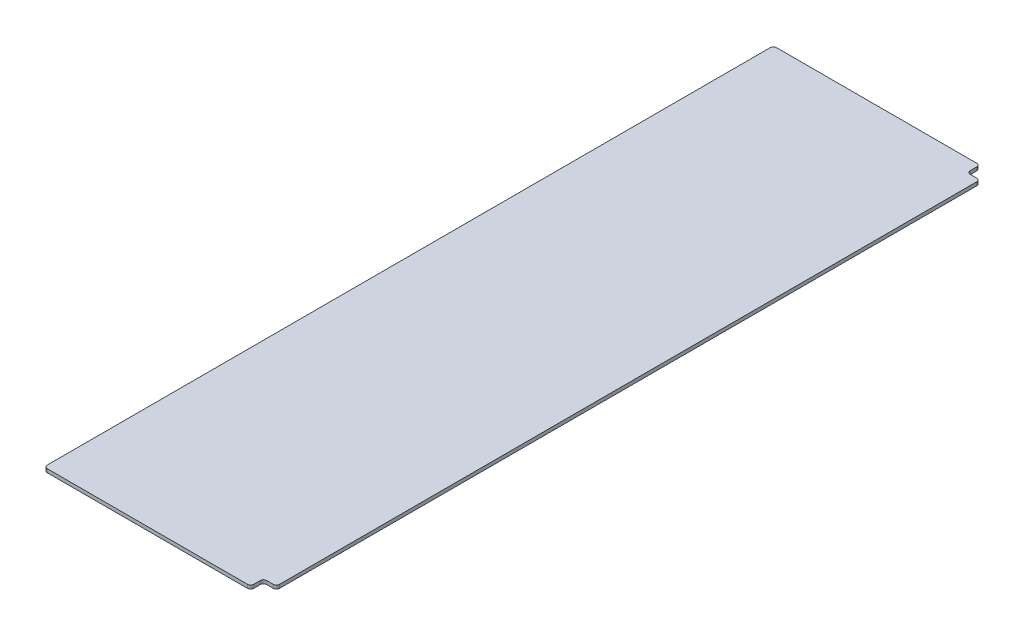
from build123d import *

# Parameters (mm, degrees)
SKETCH1_W           = 190.5
SKETCH1_H           = 609.6
BOSS_EXTRUDE1_DEPTH = 2.778125
SKETCH2_W           = 190.5
SKETCH2_H           = 17.78
CUT_EXTRUDE1_DEPTH  = 3.778125
SKETCH3_W           = 17.78
SKETCH3_H           = 574.04
CUT_EXTRUDE2_DEPTH  = 3.778125
SKETCH4_W           = 10.16
SKETCH4_H           = 10.16
CUT_EXTRUDE3_DEPTH  = 3.778125
FILLET1_R           = 2.54


with BuildPart() as part:
    # Sketch1 → Boss-Extrude1 (new body)
    with BuildSketch(Plane(origin=(0, 0, 0), x_dir=(1, 0, 0), z_dir=(0, 1, 0))):
        with Locations((95.25, 304.8)):
            Rectangle(SKETCH1_W, SKETCH1_H)
    extrude(amount=BOSS_EXTRUDE1_DEPTH)

    # Sketch2 → Cut-Extrude1 (cut, through all)
    with BuildSketch(Plane(origin=(0, 2.778125, 0), x_dir=(1, 0, 0), z_dir=(0, 1, 0))):
        with Locations((95.25, 8.89)):
            Rectangle(SKETCH2_W, SKETCH2_H)
        with Locations((95.25, 600.71)):
            Rectangle(SKETCH2_W, SKETCH2_H)
    extrude(amount=-CUT_EXTRUDE1_DEPTH, mode=Mode.SUBTRACT)

    # Sketch3 → Cut-Extrude2 (cut, through all)
    with BuildSketch(Plane(origin=(0, 2.778125, 0), x_dir=(1, 0, 0), z_dir=(0, 1, 0))):
        with Locations((8.89, 304.8)):
            Rectangle(SKETCH3_W, SKETCH3_H)
    extrude(amount=-CUT_EXTRUDE2_DEPTH, mode=Mode.SUBTRACT)

    # Sketch4 → Cut-Extrude3 (cut, through all)
    with BuildSketch(Plane(origin=(0, 2.778125, 0), x_dir=(1, 0, 0), z_dir=(0, 1, 0))):
        with Locations((185.42, 586.74)):
            Rectangle(SKETCH4_W, SKETCH4_H)
        with Locations((185.42, 22.86)):
            Rectangle(SKETCH4_W, SKETCH4_H)
    extrude(amount=-CUT_EXTRUDE3_DEPTH, mode=Mode.SUBTRACT)

    # Fillet1
    fillet1_edges = [part.edges().sort_by_distance(p)[0] for p in [
        (17.78, 1.3890625, -591.82),
        (17.78, 1.3890625, -17.78),
        (190.5, 1.3890625, -581.66),
        (180.34, 1.3890625, -581.66),
        (180.34, 1.3890625, -591.82),
        (190.5, 1.3890625, -27.94),
        (180.34, 1.3890625, -17.78),
        (180.34, 1.3890625, -27.94),
    ]]
    fillet(fillet1_edges, radius=FILLET1_R)


solid = part.part
